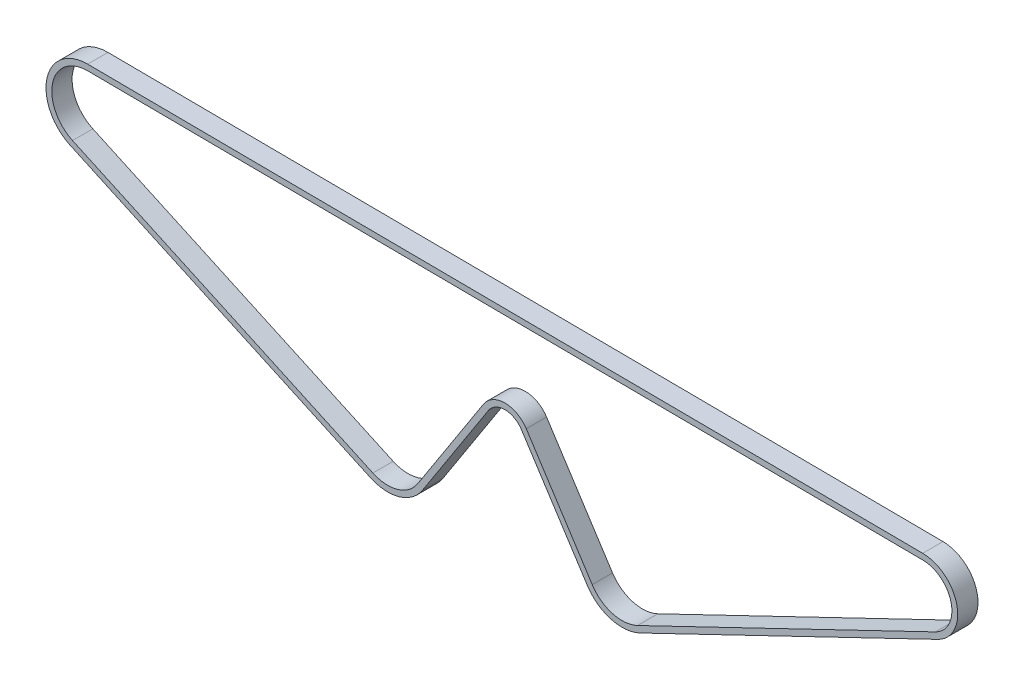
from build123d import *

# Parameters (mm, degrees)
BOSS_EXTRUDE1_DEPTH = 7


with BuildPart() as part:
    # Sketch4 → Boss-Extrude1 (new body)
    with BuildSketch(Plane.XY):
        with BuildLine():
            Line((149.215463732, 12.793345832), (46.589393766, -36.607849916))
            ThreePointArc((46.589393766, -36.607849916), (36.535868579, -37.486862399), (28.414970428, -31.495448136))
            Line((28.414970428, -31.495448136), (5.685960057, 3.674609943))
            ThreePointArc((5.685960057, 3.674609943), (0, 6.77), (-5.685960057, 3.674609943))
            Line((-5.685960057, 3.674609943), (-28.414970428, -31.495448136))
            ThreePointArc((-28.414970428, -31.495448136), (-36.408809792, -37.450485427), (-46.350175166, -36.720285855))
            Line((-46.350175166, -36.720285855), (-149.891425293, 10.779714145))
            ThreePointArc((-149.891425293, 10.779714145), (-157.871281998, 26.846306071), (-143.836659858, 38.019616704))
            Line((-143.836659858, 38.019616704), (144.030375349, 35.909673379))
            ThreePointArc((144.030375349, 35.909673379), (155.806430283, 26.411409249), (149.215463732, 12.793345832))
        make_face()
        with BuildLine():
            Line((-143.851318616, 36.019670425), (144.015716591, 33.9097271))
            ThreePointArc((144.015716591, 33.9097271), (153.854920385, 25.973677464), (148.347994384, 14.59542711))
            Line((148.347994384, 14.59542711), (45.721924419, -34.805768638))
            ThreePointArc((45.721924419, -34.805768638), (37.077442705, -35.561583857), (30.094722291, -30.409891285))
            Line((30.094722291, -30.409891285), (7.36571192, 4.760166794))
            ThreePointArc((7.36571192, 4.760166794), (0, 8.77), (-7.36571192, 4.760166794))
            Line((-7.36571192, 4.760166794), (-30.094722291, -30.409891285))
            ThreePointArc((-30.094722291, -30.409891285), (-36.968191738, -35.530305269), (-45.516233303, -34.902446212))
            Line((-45.516233303, -34.902446212), (-149.05748343, 12.597553788))
            ThreePointArc((-149.05748343, 12.597553788), (-155.918929945, 26.412345864), (-143.851318616, 36.019670425))
        make_face(mode=Mode.SUBTRACT)
    extrude(amount=BOSS_EXTRUDE1_DEPTH)


solid = part.part
